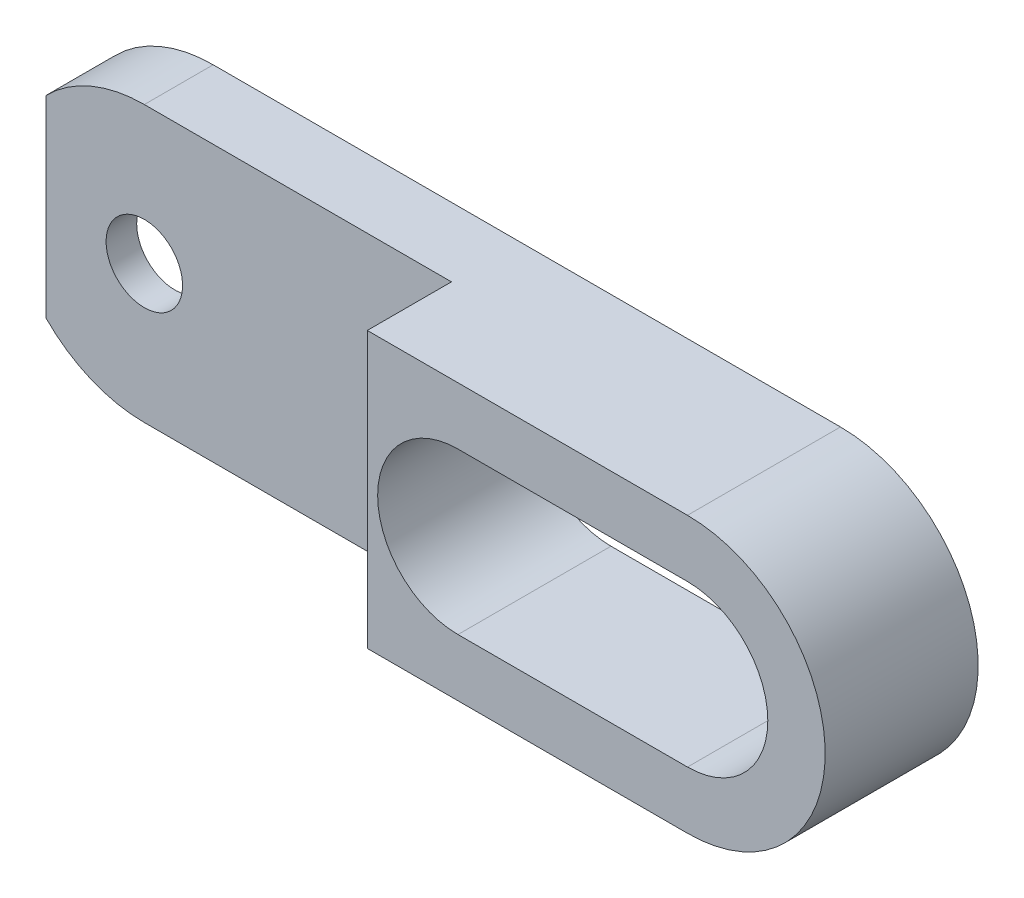
from build123d import *

# Parameters (mm, degrees)
MAIN_DEPTH          = 10
SKETCH1_W           = 26.5
SKETCH1_H           = 18
CUT_EXTRUDE1_DEPTH  = 7.5
ESQUISSE2_R         = 2.5
BOSS_EXTRUDE1_DEPTH = 2


with BuildPart() as part:
    # Esquisse1 → Main (new body)
    with BuildSketch(Plane.XY):
        with BuildLine():
            Line((-4.375785644, 4.25), (-6.426543071, 6.300757427))
            ThreePointArc((-6.426543071, 6.300757427), (-3.48519606, 8.297795395), (0, 9))
            Line((0, 9), (41, 9))
            ThreePointArc((41, 9), (50, 0), (41, -9))
            Line((41, -9), (0, -9))
            ThreePointArc((0, -9), (-3.48519606, -8.297795395), (-6.426543071, -6.300757427))
            Line((-6.426543071, -6.300757427), (-4.375785644, -4.25))
            ThreePointArc((-4.375785644, -4.25), (0, -6.1), (4.375785644, -4.25))
            Line((4.375785644, -4.25), (17.31559729, -2.78215714))
            ThreePointArc((17.31559729, -2.78215714), (19.8, 0), (17.31559729, 2.78215714))
            Line((17.31559729, 2.78215714), (4.375785644, 4.25))
            ThreePointArc((4.375785644, 4.25), (0, 6.1), (-4.375785644, 4.25))
        make_face()
        with BuildLine():
            Line((26, 5.25), (41, 5.25))
            ThreePointArc((41, 5.25), (46.25, 0), (41, -5.25))
            Line((41, -5.25), (26, -5.25))
            ThreePointArc((26, -5.25), (20.75, 0), (26, 5.25))
        make_face(mode=Mode.SUBTRACT)
    extrude(amount=MAIN_DEPTH)

    # Sketch1 → Cut-Extrude1 (cut)
    with BuildSketch(Plane.XY.offset(10)):
        with Locations((6.823456929, 0)):
            Rectangle(SKETCH1_W, SKETCH1_H)
    extrude(amount=-CUT_EXTRUDE1_DEPTH, mode=Mode.SUBTRACT)

    # Esquisse2 → Boss-Extrude1 (add)
    with BuildSketch(Plane(origin=(0, 0, 2.5), x_dir=(-1, 0, 0), z_dir=(0, 0, -1))):
        with BuildLine():
            Line((0, -9), (-20.073456929, -9))
            Line((-20.073456929, -9), (-20.073456929, 9))
            Line((-20.073456929, 9), (0, 9))
            ThreePointArc((0, 9), (3.48519606, 8.297795395), (6.426543071, 6.300757427))
            Line((6.426543071, 6.300757427), (6.426543071, -6.300757427))
            ThreePointArc((6.426543071, -6.300757427), (3.48519606, -8.297795395), (0, -9))
        make_face()
        Circle(ESQUISSE2_R, mode=Mode.SUBTRACT)
    extrude(amount=-BOSS_EXTRUDE1_DEPTH)


solid = part.part
